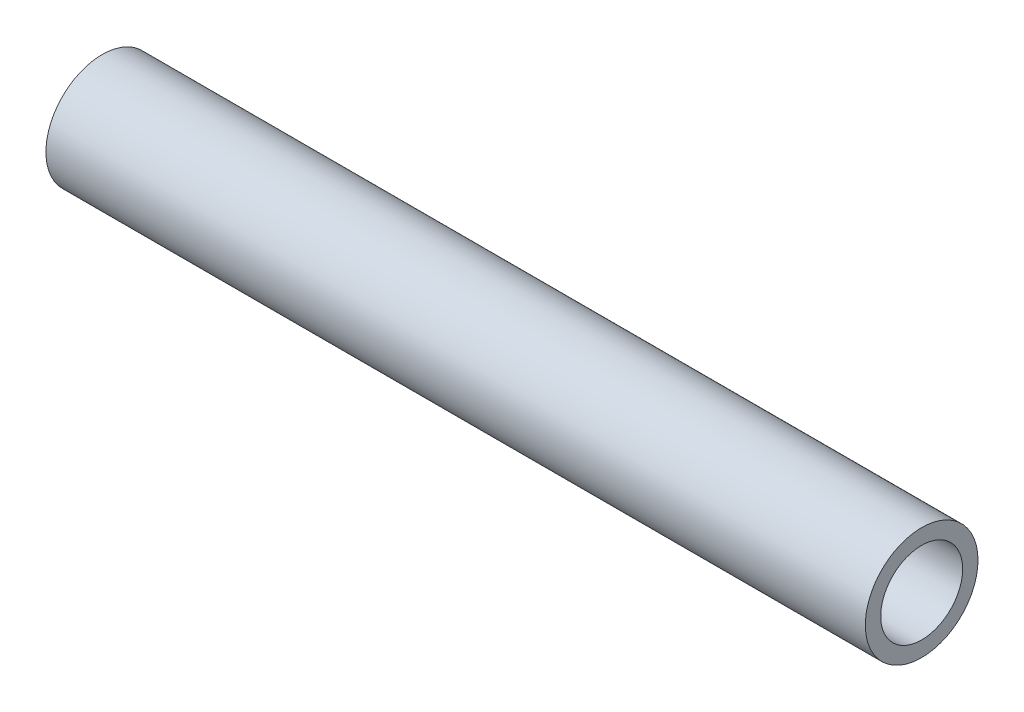
from build123d import *

# Parameters (mm, degrees)
ESQUISSE1_R        = 11
ESQUISSE1_R_2      = 8
BOSS_EXTRU_1_DEPTH = 160


with BuildPart() as part:
    # Esquisse1 → Boss.-Extru.1 (new body)
    with BuildSketch(Plane(origin=(0, 0, 0), x_dir=(0, 0, -1), z_dir=(1, 0, 0))):
        Circle(ESQUISSE1_R)
        Circle(ESQUISSE1_R_2, mode=Mode.SUBTRACT)
    extrude(amount=BOSS_EXTRU_1_DEPTH)


solid = part.part
